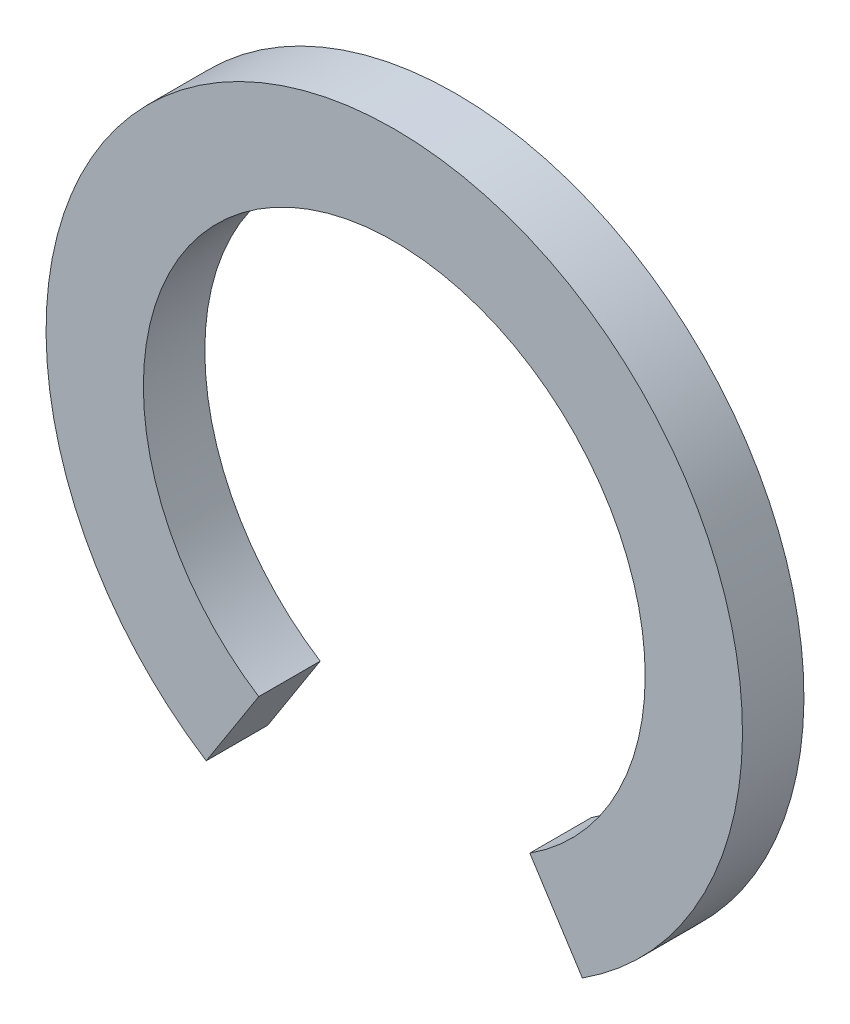
from build123d import *

# Parameters (mm, degrees)
BOSS_EXTRUDE1_DEPTH = 1.5


with BuildPart() as part:
    # Sketch1 → Boss-Extrude1 (new body)
    with BuildSketch(Plane.XY):
        with BuildLine():
            Line((-3.30825333, -5.154714823), (-4.591045437, -7.153481795))
            ThreePointArc((-4.591045437, -7.153481795), (0, 8.5), (4.591045437, -7.153481795))
            Line((4.591045437, -7.153481795), (3.30825333, -5.154714823))
            ThreePointArc((3.30825333, -5.154714823), (0, 6.125), (-3.30825333, -5.154714823))
        make_face()
    extrude(amount=BOSS_EXTRUDE1_DEPTH)


solid = part.part
